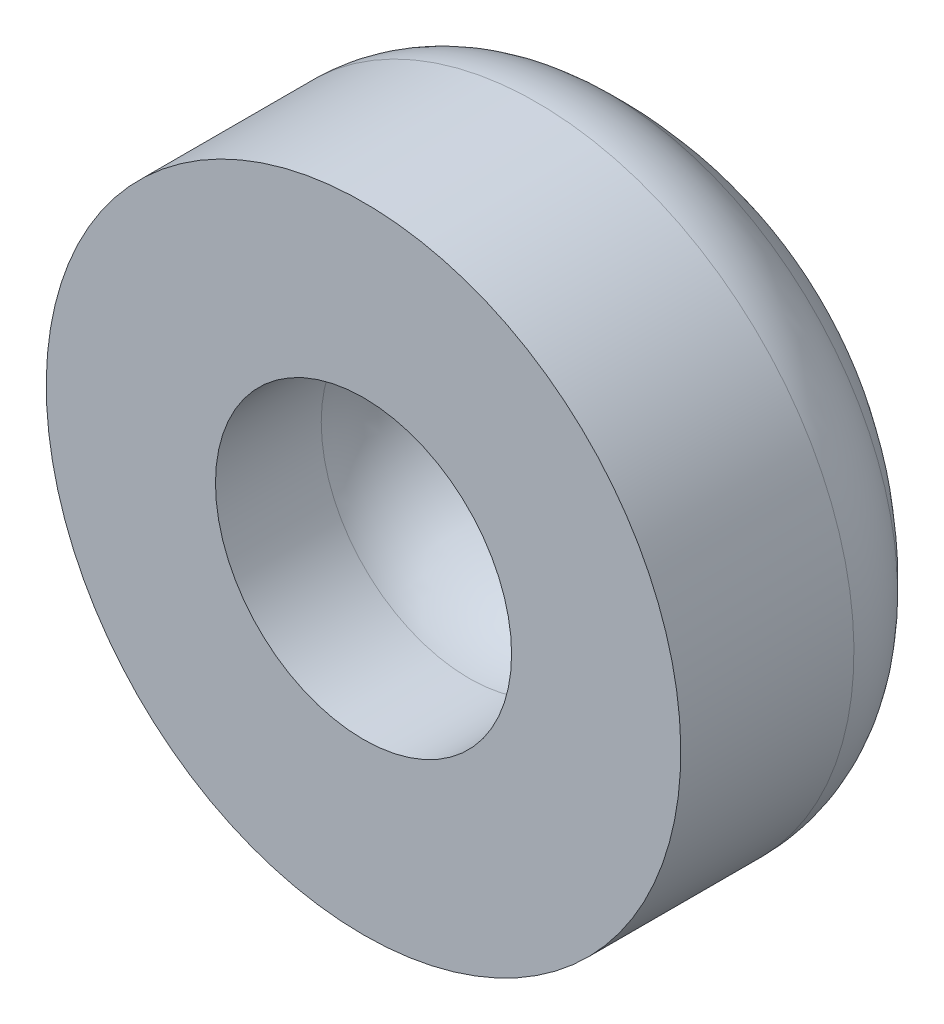
from build123d import *

# Parameters (mm, degrees)
CROQUIS1_W              = 6
CROQUIS1_H              = 8
CROQUIS1_R              = 1.4
SALIENTE_EXTRUIR1_DEPTH = 2
SALIENTE_EXTRUIR2_DEPTH = 4
CROQUIS3_W              = 6
CROQUIS3_H              = 1
SALIENTE_EXTRUIR3_DEPTH = 4
REDONDEO1_R             = 1
REDONDEO2_R             = 1


with BuildPart() as part:
    # Croquis1 → Saliente-Extruir1 (new body)
    with BuildSketch(Plane.XY):
        Rectangle(CROQUIS1_W, CROQUIS1_H)
        Circle(CROQUIS1_R, mode=Mode.SUBTRACT)
    extrude(amount=SALIENTE_EXTRUIR1_DEPTH)

    # Croquis2 → Saliente-Extruir2 (add, symmetric)
    with BuildSketch(Plane(origin=(0, 0, 0), x_dir=(1, 0, 0), z_dir=(0, 1, 0))):
        with BuildLine():
            Line((-3, 0), (3, 0))
            ThreePointArc((3, 0), (0, 1.5), (-3, 0))
        make_face()
    extrude(amount=SALIENTE_EXTRUIR2_DEPTH, both=True)

    # Croquis3 → Saliente-Extruir3 (add)
    with BuildSketch(Plane.XY.offset(2)):
        with Locations((0, 3.5)):
            Rectangle(CROQUIS3_W, CROQUIS3_H)
        with Locations((0, -3.5)):
            Rectangle(CROQUIS3_W, CROQUIS3_H)
    extrude(amount=-SALIENTE_EXTRUIR3_DEPTH)

    # Redondeo1
    redondeo1_edges = [part.edges().sort_by_distance(p)[0] for p in [
        (-1.4, 0, 0),
    ]]
    fillet(redondeo1_edges, radius=REDONDEO1_R)

    # Croquis4 → Cortar-Revolución2 (revolve, cut)
    with BuildSketch(Plane(origin=(0, 0, 0), x_dir=(0, 0, -1), z_dir=(1, 0, 0))):
        with BuildLine():
            Line((0, 3), (-2, 3))
            Line((-2, 3), (-2, 10))
            Line((-2, 10), (3, 10))
            Line((3, 10), (3, 0))
            Line((3, 0), (1.5, 0))
            ThreePointArc((1.5, 0), (1.104101966, 1.677050983), (0, 3))
        make_face()
    revolve(axis=Axis((0, 0, 2), (0, 0, -1)), mode=Mode.SUBTRACT)

    # Redondeo2
    redondeo2_edges = [part.edges().sort_by_distance(p)[0] for p in [
        (0, -3, 0),
    ]]
    fillet(redondeo2_edges, radius=REDONDEO2_R)


solid = part.part
